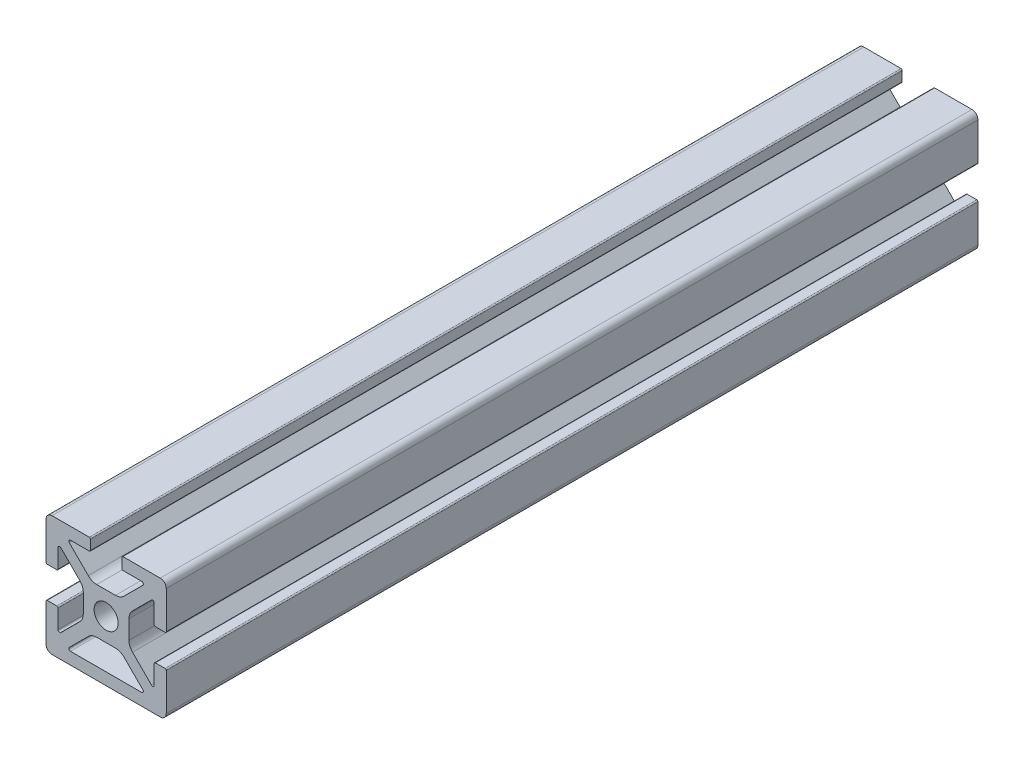
from build123d import *

# Parameters (mm, degrees)
BOSS_EXTRUDE1_DEPTH = 85.725
FILLET2_R           = 0.254
FILLET1_R           = 1.27
SKETCH5_W           = 7.112
SKETCH5_H           = 2.54
BOSS_EXTRUDE2_DEPTH = 171.45


with BuildPart() as part:
    # Sketch3 → Boss-Extrude1 (new body, symmetric)
    with BuildSketch(Plane.XY):
        with BuildLine():
            Line((-12.7, 12.7), (-1.796051224, 1.796051224))
            ThreePointArc((-1.796051224, 1.796051224), (-0.972015918, 2.346654013), (0, 2.54))
            Line((0, 2.54), (0, 4.826))
            Line((0, 4.826), (-1.977846327, 4.826))
            ThreePointArc((-1.977846327, 4.826), (-2.949862246, 5.019345987), (-3.773897552, 5.569948776))
            Line((-3.773897552, 5.569948776), (-7.772528286, 9.56857951))
            ThreePointArc((-7.772528286, 9.56857951), (-7.847628361, 9.946133082), (-7.527553898, 10.16))
            Line((-7.527553898, 10.16), (-3.302, 10.16))
            Line((-3.302, 10.16), (-3.302, 12.7))
            Line((-3.302, 12.7), (-12.7, 12.7))
        make_face()
    extrude(amount=BOSS_EXTRUDE1_DEPTH, both=True)

    # Fillet2
    fillet2_edges = [part.edges().sort_by_distance(p)[0] for p in [
        (-3.302, 12.7, 0),
        (-3.302, 10.16, 0),
    ]]
    fillet(fillet2_edges, radius=FILLET2_R)

    # Mirror1: part across plane


with BuildPart() as part_1:
    add(part.part)
    add(part.part.mirror(Plane(origin=(0, 0, 85.725), x_dir=(0, 0, 1), z_dir=(0.707106781, 0.707106781, 0))))

    # Fillet1
    fillet1_edges = [part_1.edges().sort_by_distance(p)[0] for p in [
        (-12.7, 12.7, 0),
    ]]
    fillet(fillet1_edges, radius=FILLET1_R)

    # Mirror2: part across plane


with BuildPart() as part_2:
    add(part_1.part)
    add(part_1.part.mirror(Plane(origin=(0, 0, 85.725), x_dir=(0, 0, 1), z_dir=(0, 1, 0))))

    # Mirror5: part across plane


with BuildPart() as part_3:
    add(part_2.part)
    add(part_2.part.mirror(Plane(origin=(0, 0, 85.725), x_dir=(0, 0, 1), z_dir=(-1, 0, 0))))

    # Sketch5 → Boss-Extrude2 (add, through all)
    with BuildSketch(Plane.XY.offset(85.725)):
        with Locations((0, -11.43)):
            Rectangle(SKETCH5_W, SKETCH5_H)
    extrude(amount=-BOSS_EXTRUDE2_DEPTH)


solid = part_3.part
